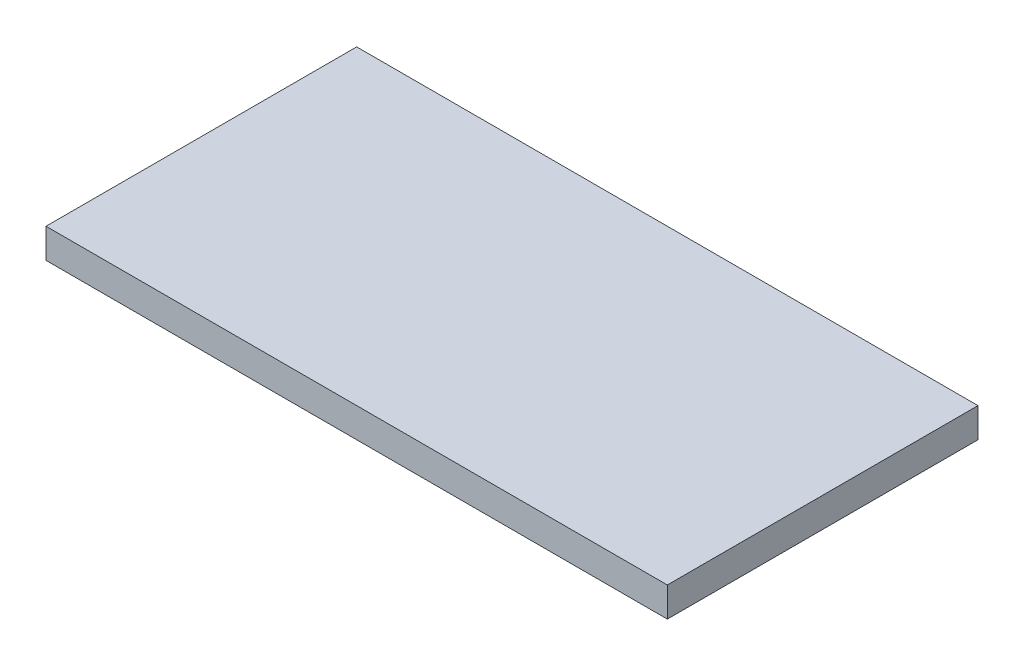
from build123d import *

# Parameters (mm, degrees)
SKETCH1_W           = 84
SKETCH1_H           = 42
BOSS_EXTRUDE1_DEPTH = 4


with BuildPart() as part:
    # Sketch1 → Boss-Extrude1 (new body)
    with BuildSketch(Plane(origin=(0, 0, 0), x_dir=(1, 0, 0), z_dir=(0, 1, 0))):
        Rectangle(SKETCH1_W, SKETCH1_H)
    extrude(amount=BOSS_EXTRUDE1_DEPTH)


solid = part.part
